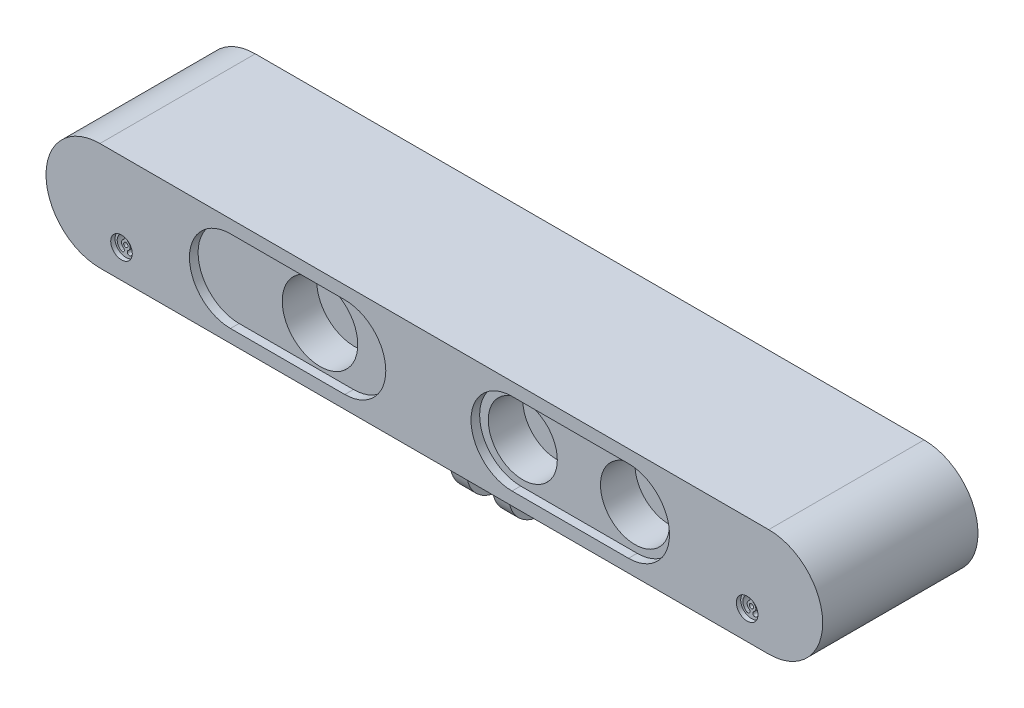
from build123d import *

# Parameters (mm, degrees)
BOSS_EXTRUDE1_DEPTH     = 36
SKETCH3_R               = 8.75
SKETCH3_R_2             = 8
CUT_EXTRUDE1_DEPTH      = 10
CUT_EXTRUDE2_DEPTH      = 2
SKETCH5_R               = 2.5
CUT_EXTRUDE3_DEPTH      = 1
SKETCH6_R               = 0.5
CUT_EXTRUDE4_DEPTH      = 5
SKETCH7_W               = 3.8
SKETCH7_H               = 15
BOSS_EXTRUDE2_DEPTH     = 17
SKETCH8_R               = 2.5
CUT_EXTRUDE5_DEPTH      = 84.2
CUT_EXTRUDE5_DEPTH_BACK = 97.8


with BuildPart() as part:
    # Sketch1 → Boss-Extrude1 (new body)
    with BuildSketch(Plane.XY):
        with BuildLine():
            Line((-77.5, 12.5), (77.5, 12.5))
            ThreePointArc((77.5, 12.5), (90, 0), (77.5, -12.5))
            Line((77.5, -12.5), (-77.5, -12.5))
            ThreePointArc((-77.5, -12.5), (-90, 0), (-77.5, 12.5))
        make_face()
    extrude(amount=-BOSS_EXTRUDE1_DEPTH)

    # Sketch3 → Cut-Extrude1 (cut)
    with BuildSketch(Plane.XY):
        with Locations((-28.5, 0)):
            Circle(SKETCH3_R)
        with Locations((18.5, 0)):
            Circle(SKETCH3_R_2)
        with Locations((44.5, 0)):
            Circle(SKETCH3_R_2)
    extrude(amount=-CUT_EXTRUDE1_DEPTH, mode=Mode.SUBTRACT)

    # Sketch4 → Cut-Extrude2 (cut)
    with BuildSketch(Plane.XY):
        with BuildLine():
            Line((-47.25, 9.5), (-20.75, 9.5))
            ThreePointArc((-20.75, 9.5), (-11.25, 0), (-20.75, -9.5))
            Line((-20.75, -9.5), (-47.25, -9.5))
            ThreePointArc((-47.25, -9.5), (-56.75, 0), (-47.25, 9.5))
        make_face()
        with BuildLine():
            Line((18, 9.5), (45, 9.5))
            ThreePointArc((45, 9.5), (54.5, 0), (45, -9.5))
            Line((45, -9.5), (18, -9.5))
            ThreePointArc((18, -9.5), (8.5, 0), (18, 9.5))
        make_face()
    extrude(amount=-CUT_EXTRUDE2_DEPTH, mode=Mode.SUBTRACT)

    # Sketch5 → Cut-Extrude3 (cut)
    with BuildSketch(Plane.XY):
        with Locations((72.5, -5.85958214)):
            Circle(SKETCH5_R)
        with Locations((-72.5, -5.85958214)):
            Circle(SKETCH5_R)
    extrude(amount=-CUT_EXTRUDE3_DEPTH, mode=Mode.SUBTRACT)

    # Sketch6 → Cut-Extrude4 (cut)
    with BuildSketch(Plane.XY):
        with Locations((-72.5, -5.85958214)):
            Circle(SKETCH6_R)
        with Locations((72.5, -5.85958214)):
            Circle(SKETCH6_R)
        with BuildLine():
            ThreePointArc((-71.394458403, -7.526248807), (-70.5, -5.85958214), (-71.394458403, -4.192915474))
            ThreePointArc((-71.394458403, -4.192915474), (-72.087510469, -4.333196741), (-71.947229202, -5.026248807))
            ThreePointArc((-71.947229202, -5.026248807), (-71.5, -5.85958214), (-71.947229202, -6.692915474))
            ThreePointArc((-71.947229202, -6.692915474), (-72.087510469, -7.385967539), (-71.394458403, -7.526248807))
        make_face()
        with BuildLine():
            ThreePointArc((-73.605541597, -4.192915474), (-74.5, -5.85958214), (-73.605541597, -7.526248807))
            ThreePointArc((-73.605541597, -7.526248807), (-72.912489531, -7.385967539), (-73.052770798, -6.692915474))
            ThreePointArc((-73.052770798, -6.692915474), (-73.5, -5.85958214), (-73.052770798, -5.026248807))
            ThreePointArc((-73.052770798, -5.026248807), (-72.912489531, -4.333196741), (-73.605541597, -4.192915474))
        make_face()
        with BuildLine():
            ThreePointArc((73.605541597, -7.526248807), (74.5, -5.85958214), (73.605541597, -4.192915474))
            ThreePointArc((73.605541597, -4.192915474), (72.912489531, -4.333196741), (73.052770798, -5.026248807))
            ThreePointArc((73.052770798, -5.026248807), (73.5, -5.85958214), (73.052770798, -6.692915474))
            ThreePointArc((73.052770798, -6.692915474), (72.912489531, -7.385967539), (73.605541597, -7.526248807))
        make_face()
        with BuildLine():
            ThreePointArc((71.394458403, -4.192915474), (70.5, -5.85958214), (71.394458403, -7.526248807))
            ThreePointArc((71.394458403, -7.526248807), (72.087510469, -7.385967539), (71.947229202, -6.692915474))
            ThreePointArc((71.947229202, -6.692915474), (71.5, -5.85958214), (71.947229202, -5.026248807))
            ThreePointArc((71.947229202, -5.026248807), (72.087510469, -4.333196741), (71.394458403, -4.192915474))
        make_face()
    extrude(amount=-CUT_EXTRUDE4_DEPTH, mode=Mode.SUBTRACT)

    # Sketch7 → Boss-Extrude2 (add)
    with BuildSketch(Plane.XZ.offset(12.5)):
        with Locations((4.9, -18)):
            Rectangle(SKETCH7_W, SKETCH7_H)
        with Locations((-4.9, -18)):
            Rectangle(SKETCH7_W, SKETCH7_H)
    extrude(amount=BOSS_EXTRUDE2_DEPTH)

    # Sketch8 → Cut-Extrude5 (cut, two sides)
    with BuildSketch(Plane.ZY.offset(6.8)) as cut_extrude5_sk:
        with Locations((-18, -21.484376944)):
            Circle(SKETCH8_R)
        with BuildLine():
            Line((-10.5, -21), (-7.903352706, -21))
            Line((-7.903352706, -21), (-7.606016941, -33.928608258))
            Line((-7.606016941, -33.928608258), (-27.603723976, -34.388521143))
            Line((-27.603723976, -34.388521143), (-27.603723976, -21))
            Line((-27.603723976, -21), (-25.5, -21))
            ThreePointArc((-25.5, -21), (-18, -29.00000207), (-10.5, -21))
        make_face()
    extrude(amount=CUT_EXTRUDE5_DEPTH, mode=Mode.SUBTRACT)
    extrude(cut_extrude5_sk.sketch, amount=-CUT_EXTRUDE5_DEPTH_BACK, mode=Mode.SUBTRACT)


solid = part.part
